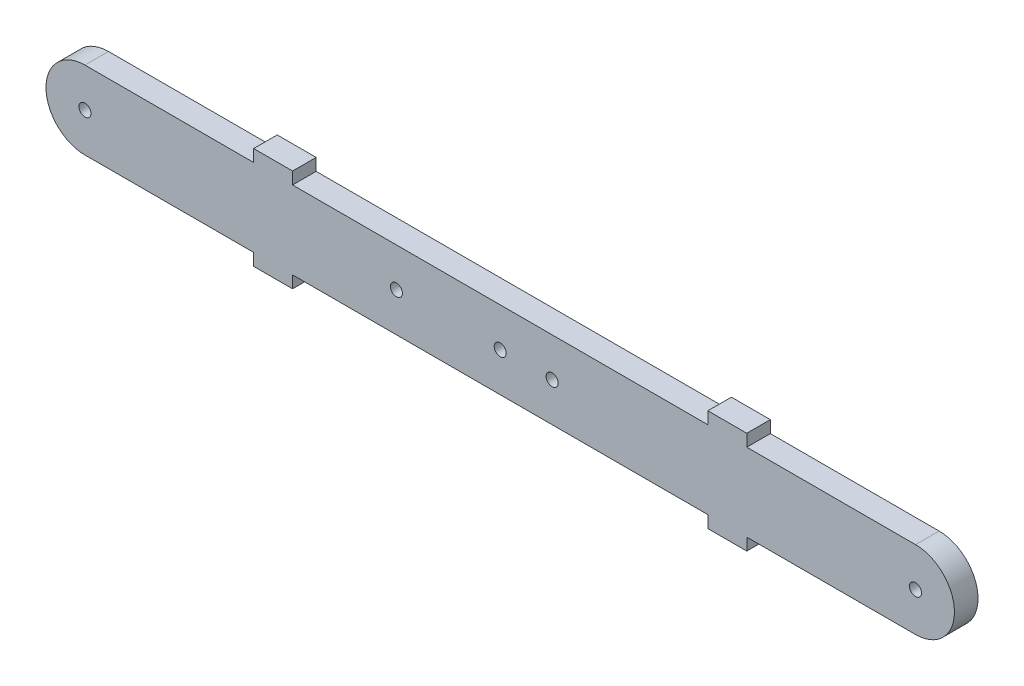
from build123d import *

# Parameters (mm, degrees)
SKETCH1_R             = 1.4732
BOSS_EXTRUDE1_DEPTH   = 5.7658
F_4_CLEARANCE_HOLE1_D = 2.9464
SKETCH5_W             = 9.525
SKETCH5_H             = 2.9591
BOSS_EXTRUDE2_DEPTH   = 5.7658


with BuildPart() as part:
    # Sketch1 → Boss-Extrude1 (new body)
    with BuildSketch(Plane.XY):
        with BuildLine():
            Line((-101.6, 9.525), (101.6, 9.525))
            ThreePointArc((101.6, 9.525), (111.125, 0), (101.6, -9.525))
            Line((101.6, -9.525), (-101.6, -9.525))
            ThreePointArc((-101.6, -9.525), (-111.125, 0), (-101.6, 9.525))
        make_face()
        with Locations((-101.6, 0)):
            Circle(SKETCH1_R, mode=Mode.SUBTRACT)
        with Locations((101.6, 0)):
            Circle(SKETCH1_R, mode=Mode.SUBTRACT)
    extrude(amount=BOSS_EXTRUDE1_DEPTH)

    # #4 Clearance Hole1 (through all)
    with Locations(Plane.XY.offset(5.7658)):
        with Locations((-25.4, 0), (12.7, 0), (0, 0)):
            Hole(F_4_CLEARANCE_HOLE1_D / 2)

    # Sketch5 → Boss-Extrude2 (add)
    with BuildSketch(Plane.XY.offset(5.7658)):
        with Locations((55.5625, 11.00455)):
            Rectangle(SKETCH5_W, SKETCH5_H)
        with Locations((-55.5625, 11.00455)):
            Rectangle(SKETCH5_W, SKETCH5_H)
        with Locations((-55.5625, -11.00455)):
            Rectangle(SKETCH5_W, SKETCH5_H)
        with Locations((55.5625, -11.00455)):
            Rectangle(SKETCH5_W, SKETCH5_H)
    extrude(amount=-BOSS_EXTRUDE2_DEPTH)


solid = part.part
